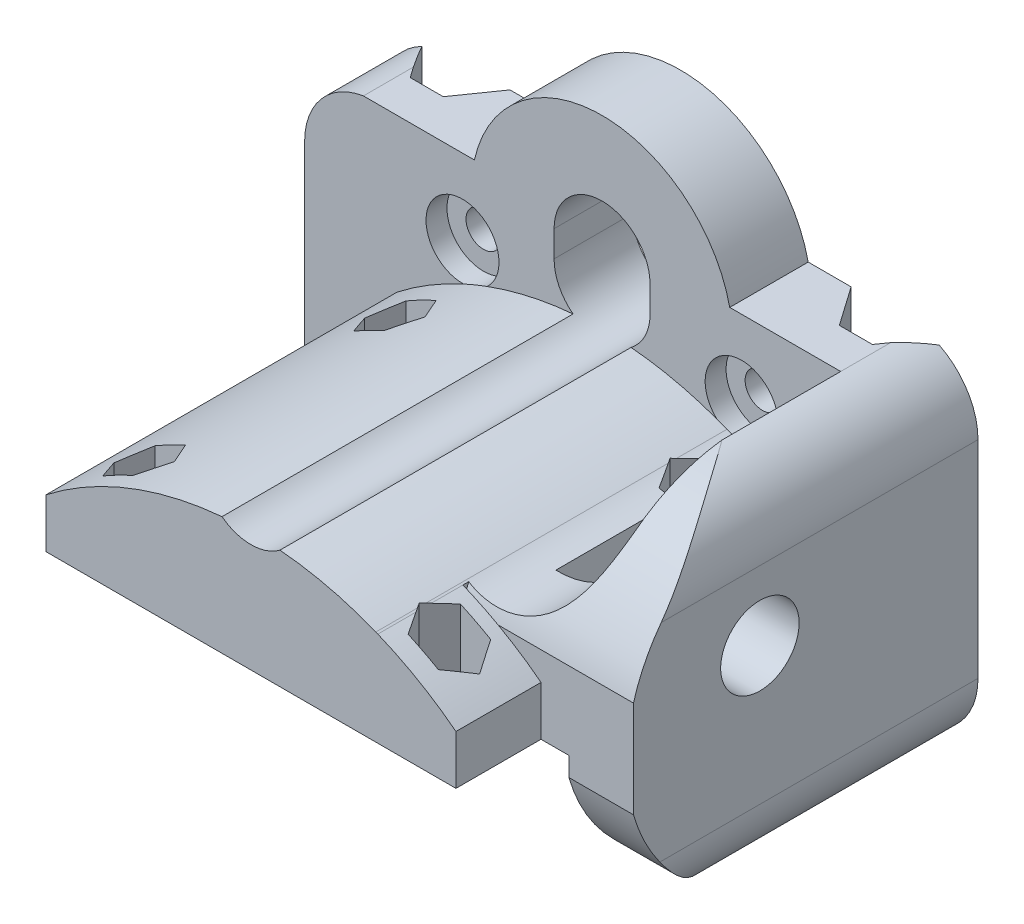
from build123d import *

# Parameters (mm, degrees)
SKETCH1_R                = 2.000043321
SKETCH1_R_2              = 2.000014119
BOSS_EXTRUDE1_DEPTH      = 4.5
CUT_EXTRUDE2_DEPTH       = 46.343813751
SKETCH6_W                = 23.5
SKETCH6_H                = 5.65
BOSS_EXTRUDE2_DEPTH      = 40.25
SKETCH3_R                = 4.181725
CUT_EXTRUDE3_DEPTH       = 2.4
BOSS_EXTRUDE3_DEPTH      = 30.5
SKETCH21_W               = 12.385700762
SKETCH21_H               = 18.597289034
CUT_EXTRUDE16_DEPTH      = 60.959352444
CUT_EXTRUDE20_DEPTH      = 19.55588
CUT_EXTRUDE21_DEPTH      = 64.068406998
CUT_EXTRUDE21_DEPTH_BACK = 64.068406998
SKETCH9_7_R              = 1.8
CUT_EXTRUDE6_DEPTH       = 64.068406998
CUT_EXTRUDE6_DEPTH_BACK  = 4.1004
SKETCH9_R                = 1.8
CUT_EXTRUDE5_DEPTH       = 64.068406927
CUT_EXTRUDE5_DEPTH_BACK  = 64.068406927
SKETCH32_R               = 4.496907104
CUT_EXTRUDE28_DEPTH      = 7.399999239


with BuildPart() as part:
    # Sketch1 → Boss-Extrude1 (new, symmetric)
    with BuildSketch(Plane.XY):
        with BuildLine():
            ThreePointArc((27.3591, -22.750023286), (32.18573506, -20.04264062), (34.100000001, -14.850154064))
            Line((34.100000001, -14.850154064), (34.100000001, 8.850156137))
            ThreePointArc((34.100000001, 8.850156137), (32.18573506, 14.042642693), (27.3591, 16.750025358))
            Line((27.3591, 16.750025358), (14.6356, 16.750025358))
            ThreePointArc((14.6356, 16.750025358), (0, 28.500025358), (-14.6356, 16.750025358))
            Line((-14.6356, 16.750025358), (-27.3591, 16.750025358))
            ThreePointArc((-27.3591, 16.750025358), (-32.18573506, 14.042642693), (-34.100000001, 8.850156137))
            Line((-34.100000001, 8.850156137), (-34.100000001, -14.850154064))
            ThreePointArc((-34.100000001, -14.850154064), (-32.18573506, -20.04264062), (-27.3591, -22.750023286))
            Line((-27.3591, -22.750023286), (-11.500037792, -22.750023286))
            ThreePointArc((-11.500037792, -22.750023286), (-8.671570628, -21.578433826), (-7.499981167, -18.749966661))
            Line((-7.499981167, -18.749966661), (-7.499981167, -16.089239323))
            ThreePointArc((-7.499981167, -16.089239323), (-7.500113179, -16.044739987), (-7.499981167, -16.000240651))
            ThreePointArc((-7.499981167, -16.000240651), (0, -8.544626807), (7.499981167, -16.000240651))
            ThreePointArc((7.499981167, -16.000240651), (7.500113179, -16.044739987), (7.499981167, -16.089239323))
            Line((7.499981167, -16.089239323), (7.499981167, -18.749966661))
            ThreePointArc((7.499981167, -18.749966661), (8.671570628, -21.578433826), (11.500037792, -22.750023286))
            Line((11.500037792, -22.750023286), (27.3591, -22.750023286))
        make_face()
        with Locations((-16.000068831, -16.5)):
            Circle(SKETCH1_R, mode=Mode.SUBTRACT)
        with Locations((16.000068831, -16.5)):
            Circle(SKETCH1_R, mode=Mode.SUBTRACT)
        with Locations((-16.000068831, 7.999981023)):
            Circle(SKETCH1_R_2, mode=Mode.SUBTRACT)
        with Locations((16.000068831, 7.999981023)):
            Circle(SKETCH1_R_2, mode=Mode.SUBTRACT)
    extrude(amount=BOSS_EXTRUDE1_DEPTH, both=True)

    # Sketch4 → Cut-Extrude2 (cut, through all)
    with BuildSketch(Plane.XY.offset(4.5)):
        with BuildLine():
            Line((5.5, 11.5), (5.5, 14.5))
            ThreePointArc((5.5, 14.5), (0, 20), (-5.5, 14.5))
            Line((-5.5, 14.5), (-5.5, 11.5))
            ThreePointArc((-5.5, 11.5), (0, 6), (5.5, 11.5))
        make_face()
    extrude(amount=-CUT_EXTRUDE2_DEPTH, mode=Mode.SUBTRACT)

    # Sketch6 → Boss-Extrude2 (add)
    with BuildSketch(Plane.XY.offset(4.5)):
        with Locations((11.75, -3.625)):
            Rectangle(SKETCH6_W, SKETCH6_H)
        with Locations((-11.75, -3.625)):
            Rectangle(SKETCH6_W, SKETCH6_H)
        with BuildLine():
            Line((0, -0.8), (23.5, -0.8))
            ThreePointArc((23.5, -0.8), (13.984131025, 4.616883926), (3.324005419, 7.118106805))
            ThreePointArc((3.324005419, 7.118106805), (0, 6), (-3.324005419, 7.118106805))
            ThreePointArc((-3.324005419, 7.118106805), (-13.984131025, 4.616883926), (-23.5, -0.8))
            Line((-23.5, -0.8), (0, -0.8))
        make_face()
    extrude(amount=BOSS_EXTRUDE2_DEPTH)

    # Sketch3 → Cut-Extrude3 (cut)
    with BuildSketch(Plane.XY.offset(4.5)):
        with Locations((-16.000068831, 7.999981023)):
            Circle(SKETCH3_R)
        with Locations((16.000068831, 7.999981023)):
            Circle(SKETCH3_R)
        with Locations((16.000068831, -16.500018977)):
            Circle(SKETCH3_R)
        with Locations((-16.000068831, -16.500018977)):
            Circle(SKETCH3_R)
    extrude(amount=-CUT_EXTRUDE3_DEPTH, mode=Mode.SUBTRACT)

    # Sketch15 → Boss-Extrude3 (add)
    with BuildSketch(Plane.XY.offset(4.5)):
        with BuildLine():
            Line((14.314300001, 16.750025358), (14.314300001, -22.750023286))
            Line((14.314300001, -22.750023286), (27.3591, -22.750023286))
            ThreePointArc((27.3591, -22.750023286), (32.18573506, -20.04264062), (34.100000001, -14.850154064))
            Line((34.100000001, -14.850154064), (34.100000001, 8.850156137))
            ThreePointArc((34.100000001, 8.850156137), (32.18573506, 14.042642693), (27.3591, 16.750025358))
            Line((27.3591, 16.750025358), (14.314300001, 16.750025358))
        make_face()
    extrude(amount=BOSS_EXTRUDE3_DEPTH)

    # Sketch21 → Cut-Extrude16 (cut, through all)
    with BuildSketch(Plane.XY.offset(4.5)):
        with Locations((20.507150382, -15.748644517)):
            Rectangle(SKETCH21_W, SKETCH21_H)
        with BuildLine():
            ThreePointArc((27.3591, 12.579600334), (22.93090056, 5.157449584), (14.314300001, 4.485536757))
            Line((14.314300001, 4.485536757), (14.314300001, 16.750025358))
            Line((14.314300001, 16.750025358), (27.3591, 16.750025358))
            Line((27.3591, 16.750025358), (27.3591, 12.579600334))
        make_face()
    extrude(amount=CUT_EXTRUDE16_DEPTH, mode=Mode.SUBTRACT)

    # Sketch22 → Cut-Extrude20 (cut)
    with BuildSketch(Plane(origin=(34.100000001, 0, 0), x_dir=(0, 0, -1), z_dir=(1, 0, 0))):
        with BuildLine():
            Line((-35, 18.44611001), (-35, 2.44611001))
            ThreePointArc((-35, 2.44611001), (-28.722119173, 12.152830277), (-18.115600586, 16.75))
            Line((-18.115600586, 16.75), (-18.115600586, 18.44611001))
            Line((-18.115600586, 18.44611001), (-35, 18.44611001))
        make_face()
        with BuildLine():
            ThreePointArc((-19.450399399, -22.75), (-29.235735953, -17.914679764), (-35, -8.646109581))
            Line((-35, -8.646109581), (-35, -24.646109581))
            Line((-35, -24.646109581), (-19.450399399, -24.646109581))
            Line((-19.450399399, -24.646109581), (-19.450399399, -22.75))
        make_face()
    extrude(amount=-CUT_EXTRUDE20_DEPTH, mode=Mode.SUBTRACT)

    # Sketch24 → Cut-Extrude21 (cut, two sides)
    with BuildSketch(Plane(origin=(0, 0, 0), x_dir=(1, 0, 0), z_dir=(0, 1, 0))) as cut_extrude21_sk:
        Polygon((17.75, -16.135499954), (19.635499954, -14.25), (26.700000763, -14.25), (26.700000763, -27.549999237), (17.75, -27.549999237), align=None)
    extrude(amount=CUT_EXTRUDE21_DEPTH, mode=Mode.SUBTRACT)
    extrude(cut_extrude21_sk.sketch, amount=-CUT_EXTRUDE21_DEPTH_BACK, mode=Mode.SUBTRACT)

    # Sketch9_7 → Cut-Extrude6 (cut, two sides)
    with BuildSketch(Plane(origin=(0, 0, 0), x_dir=(1, 0, 0), z_dir=(0, 1, 0))) as cut_extrude6_sk:
        Polygon((-14.035898385, -39.5), (-15.767949192, -36.5), (-19.232050808, -36.5), (-20.964101615, -39.5), (-19.232050808, -42.5), (-15.767949192, -42.5), align=None)
        with Locations(Location((-17.5, -39.5, 0), (0, 0, 90))):
            Circle(SKETCH9_7_R, mode=Mode.SUBTRACT)
        Polygon((15.767949192, -36.5), (19.232050808, -36.5), (20.964101615, -39.5), (19.232050808, -42.5), (15.767949192, -42.5), (14.035898385, -39.5), align=None)
        with Locations(Location((17.5, -39.5, 0), (0, 0, 90))):
            Circle(SKETCH9_7_R, mode=Mode.SUBTRACT)
        Polygon((14.035898385, -10.744445), (15.767949192, -13.744445), (19.232050808, -13.744445), (20.964101615, -10.744445), (19.232050808, -7.744445), (15.767949192, -7.744445), align=None)
        with Locations(Location((17.5, -10.744445, 0), (0, 0, 90))):
            Circle(SKETCH9_7_R, mode=Mode.SUBTRACT)
        Polygon((-15.767949192, -13.744445), (-19.232050808, -13.744445), (-20.964101615, -10.744445), (-19.232050808, -7.744445), (-15.767949192, -7.744445), (-14.035898385, -10.744445), align=None)
        with Locations(Location((-17.5, -10.744445, 0), (0, 0, 90))):
            Circle(SKETCH9_7_R, mode=Mode.SUBTRACT)
    extrude(amount=CUT_EXTRUDE6_DEPTH, mode=Mode.SUBTRACT)
    extrude(cut_extrude6_sk.sketch, amount=-CUT_EXTRUDE6_DEPTH_BACK, mode=Mode.SUBTRACT)

    # Sketch9 → Cut-Extrude5 (cut, two sides)
    with BuildSketch(Plane(origin=(0, 0, 0), x_dir=(1, 0, 0), z_dir=(0, 1, 0))) as cut_extrude5_sk:
        with Locations(Location((-17.5, -39.5, 0), (0, 0, 90))):
            Circle(SKETCH9_R)
        with Locations(Location((17.5, -39.5, 0), (0, 0, 90))):
            Circle(SKETCH9_R)
        with Locations(Location((-17.5, -10.744445, 0), (0, 0, 90))):
            Circle(SKETCH9_R)
        Polygon((-22.70606608, 0), (-19.555132158, 4.5), (-29.647000001, 4.5), (-26.49606608, 0), align=None)
        Polygon((19.555132158, 4.5), (29.647000001, 4.5), (26.49606608, 0), (22.70606608, 0), align=None)
        with Locations(Location((17.5, -10.744445, 0), (0, 0, 90))):
            Circle(SKETCH9_R)
    extrude(amount=CUT_EXTRUDE5_DEPTH, mode=Mode.SUBTRACT)
    extrude(cut_extrude5_sk.sketch, amount=-CUT_EXTRUDE5_DEPTH_BACK, mode=Mode.SUBTRACT)

    # Sketch32 → Cut-Extrude28 (cut)
    with BuildSketch(Plane(origin=(34.100000001, 0, 0), x_dir=(0, 0, -1), z_dir=(1, 0, 0))):
        with Locations((-20.505386522, 0.902118416)):
            Circle(SKETCH32_R)
    extrude(amount=-CUT_EXTRUDE28_DEPTH, mode=Mode.SUBTRACT)


solid = part.part
